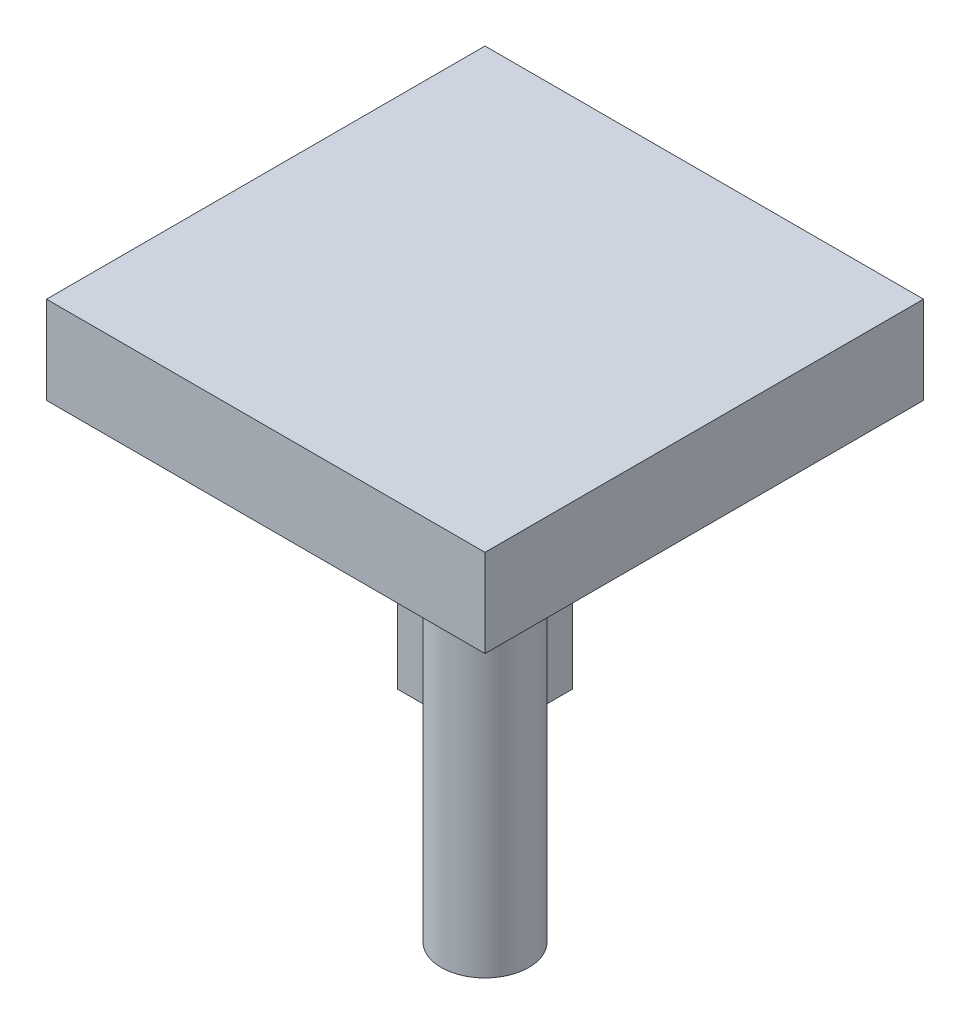
from build123d import *

# Parameters (mm, degrees)
SKETCH1_W           = 100
SKETCH1_H           = 100
BOSS_EXTRUDE1_DEPTH = 20


with BuildPart() as part:
    # Sketch1 → Boss-Extrude1 (new body)
    with BuildSketch(Plane(origin=(0, 0, 0), x_dir=(1, 0, 0), z_dir=(0, 1, 0))):
        Rectangle(SKETCH1_W, SKETCH1_H)
    extrude(amount=BOSS_EXTRUDE1_DEPTH)


solid = part.part
